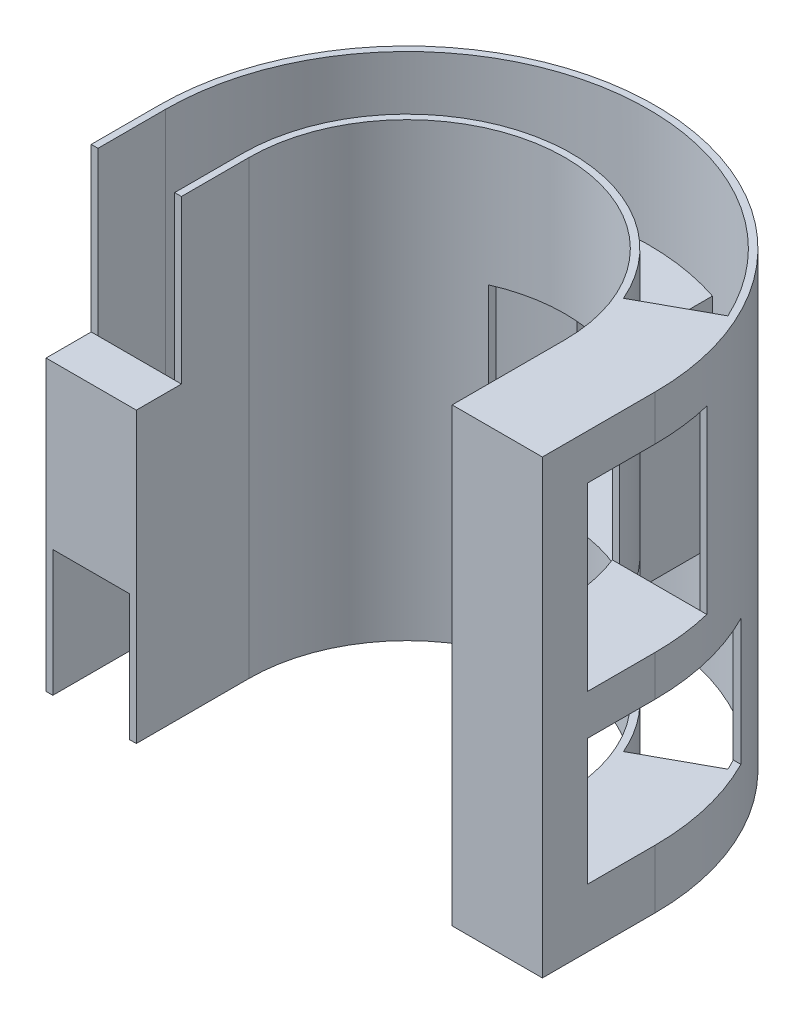
from build123d import *

# Parameters (mm, degrees)
SKETCH2_R            = 27.5
BOSS_EXTRUDE1_DEPTH  = 50
SKETCH3_R            = 26.75
CUT_EXTRUDE1_DEPTH   = 51
SKETCH7_R            = 18.25
BOSS_EXTRUDE3_DEPTH  = 50
SKETCH8_R            = 17.5
CUT_EXTRUDE3_DEPTH   = 51
SKETCH9_W            = 59.961193285
SKETCH9_H            = 28.516087398
CUT_EXTRUDE4_DEPTH   = 51
SKETCH10_W           = 0.75
SKETCH10_H           = 12.5
BOSS_EXTRUDE4_DEPTH  = 50
BOSS_EXTRUDE5_DEPTH  = 5
BOSS_EXTRUDE6_DEPTH  = 6.5
SKETCH12_W           = 14
SKETCH12_H           = 20
SKETCH12_W_2         = 20
SKETCH12_H_2         = 14
CUT_EXTRUDE6_DEPTH   = 15
SKETCH14_W           = 14
SKETCH14_H           = 20
CUT_EXTRUDE7_DEPTH   = 45
SKETCH15_W           = 16.605878589
SKETCH15_H           = 22.2356131
CUT_EXTRUDE8_DEPTH   = 15
BOSS_EXTRUDE8_DEPTH  = 4.5
BOSS_EXTRUDE9_DEPTH  = 2
BOSS_EXTRUDE10_DEPTH = 2
BOSS_EXTRUDE15_DEPTH = 24
BOSS_EXTRUDE17_DEPTH = 10
SKETCH26_W           = 5
SKETCH26_H           = 18
BOSS_EXTRUDE18_DEPTH = 10
SKETCH27_W           = 8.5
SKETCH27_H           = 14
BOSS_EXTRUDE19_DEPTH = 5


with BuildPart() as part:
    # Sketch2 → Boss-Extrude1 (new body)
    with BuildSketch(Plane(origin=(0, 0, 0), x_dir=(1, 0, 0), z_dir=(0, 1, 0))):
        Circle(SKETCH2_R)
    extrude(amount=BOSS_EXTRUDE1_DEPTH)

    # Sketch3 → Cut-Extrude1 (cut, through all)
    with BuildSketch(Plane(origin=(0, 50, 0), x_dir=(1, 0, 0), z_dir=(0, 1, 0))):
        Circle(SKETCH3_R)
    extrude(amount=-CUT_EXTRUDE1_DEPTH, mode=Mode.SUBTRACT)


with BuildPart() as body_2:
    # Sketch7 → Boss-Extrude3 (new body)
    with BuildSketch(Plane(origin=(0, 50, 0), x_dir=(1, 0, 0), z_dir=(0, 1, 0))):
        Circle(SKETCH7_R)
    extrude(amount=-BOSS_EXTRUDE3_DEPTH)

    # Sketch8 → Cut-Extrude3 (cut, through all)
    with BuildSketch(Plane(origin=(0, 50, 0), x_dir=(1, 0, 0), z_dir=(0, 1, 0))):
        Circle(SKETCH8_R)
    extrude(amount=-CUT_EXTRUDE3_DEPTH, mode=Mode.SUBTRACT)


with BuildPart() as cut_extrude4_tool:
    # Sketch9 → Cut-Extrude4 (new body, through all)
    with BuildSketch(Plane(origin=(0, 50, 0), x_dir=(1, 0, 0), z_dir=(0, 1, 0))):
        with Locations((-0.477134602, -14.258043699)):
            Rectangle(SKETCH9_W, SKETCH9_H)
    extrude(amount=-CUT_EXTRUDE4_DEPTH)


with BuildPart() as part_1:
    add(part.part)

    # Cut-Extrude4: cut by cut_extrude4_tool
    add(cut_extrude4_tool.part, mode=Mode.SUBTRACT)



with BuildPart() as body_2_1:
    add(body_2.part)

    # Cut-Extrude4: cut by cut_extrude4_tool
    add(cut_extrude4_tool.part, mode=Mode.SUBTRACT)


with BuildPart() as part_2:
    add(part_1.part)

    add(body_2_1.part)  # Boss-Extrude4 merges body 2
    # Sketch10 → Boss-Extrude4 (add)
    with BuildSketch(Plane(origin=(0, 50, 0), x_dir=(1, 0, 0), z_dir=(0, 1, 0))):
        with Locations((-27.125, -6.25)):
            Rectangle(SKETCH10_W, SKETCH10_H)
        with Locations((-17.875, -6.25)):
            Rectangle(SKETCH10_W, SKETCH10_H)
        with Locations((17.875, -6.25)):
            Rectangle(SKETCH10_W, SKETCH10_H)
        with Locations((27.125, -6.25)):
            Rectangle(SKETCH10_W, SKETCH10_H)
    extrude(amount=-BOSS_EXTRUDE4_DEPTH)

    # Sketch11 → Boss-Extrude5 (add)
    with BuildSketch(Plane(origin=(0, 50, 0), x_dir=(1, 0, 0), z_dir=(0, 1, 0))):
        with BuildLine():
            Line((16.760723177, 7.220848882), (24.236408431, 11.320733473))
            ThreePointArc((24.236408431, 11.320733473), (26.114042444, 5.798214142), (26.75, 0))
            Line((26.75, 0), (26.75, -12.5))
            Line((26.75, -12.5), (18.25, -12.5))
            Line((18.25, -12.5), (18.25, 0))
            ThreePointArc((18.25, 0), (17.873803428, 3.686414384), (16.760723177, 7.220848882))
        make_face()
    extrude(amount=-BOSS_EXTRUDE5_DEPTH)

    # Sketch13 → Boss-Extrude6 (add)
    with BuildSketch(Plane.XZ):
        with BuildLine():
            Line((18.25, 0), (18.25, 12.5))
            Line((18.25, 12.5), (26.75, 12.5))
            Line((26.75, 12.5), (26.75, 0))
            ThreePointArc((26.75, 0), (26.114042444, -5.798214142), (24.236408431, -11.320733473))
            Line((24.236408431, -11.320733473), (16.760723177, -7.220848882))
            ThreePointArc((16.760723177, -7.220848882), (17.873803428, -3.686414384), (18.25, 0))
        make_face()
    extrude(amount=-BOSS_EXTRUDE6_DEPTH)

    # Sketch12 → Cut-Extrude6 (cut)
    with BuildSketch(Plane(origin=(27.5, 0, 0), x_dir=(0, 0, -1), z_dir=(1, 0, 0))):
        with Locations((-0.5, 35)):
            Rectangle(SKETCH12_W, SKETCH12_H)
        with Locations((2.5, 13.5)):
            Rectangle(SKETCH12_W_2, SKETCH12_H_2)
    extrude(amount=-CUT_EXTRUDE6_DEPTH, mode=Mode.SUBTRACT)

    # Sketch14 → Cut-Extrude7 (cut)
    with BuildSketch(Plane.XY.offset(12.5)):
        with Locations((0, 25)):
            Rectangle(SKETCH14_W, SKETCH14_H)
    extrude(amount=-CUT_EXTRUDE7_DEPTH, mode=Mode.SUBTRACT)

    # Sketch15 → Cut-Extrude8 (cut)
    with BuildSketch(Plane.ZY.offset(27.5)):
        with Locations((15.802939295, 43.11780655)):
            Rectangle(SKETCH15_W, SKETCH15_H)
    extrude(amount=-CUT_EXTRUDE8_DEPTH, mode=Mode.SUBTRACT)

    # Sketch17 → Boss-Extrude8 (add)
    with BuildSketch(Plane(origin=(0, 25, 0), x_dir=(1, 0, 0), z_dir=(0, 1, 0))):
        with BuildLine():
            Line((26.720778432, 6.5), (17.053225501, 6.5))
            ThreePointArc((17.053225501, 6.5), (17.948312809, 3.304628164), (18.25, 0))
            Line((18.25, 0), (18.25, -7.5))
            Line((18.25, -7.5), (27.5, -7.5))
            Line((27.5, -7.5), (27.5, 0))
            ThreePointArc((27.5, 0), (27.304499692, 3.273270011), (26.720778432, 6.5))
        make_face()
    extrude(amount=-BOSS_EXTRUDE8_DEPTH)

    # Sketch18 → Boss-Extrude9 (add)
    with BuildSketch(Plane.XZ.offset(-35)):
        with BuildLine():
            Line((-7, -16.854153791), (-7, -25.817871717))
            ThreePointArc((-7, -25.817871717), (0, -26.75), (7, -25.817871717))
            Line((7, -25.817871717), (7, -16.854153791))
            ThreePointArc((7, -16.854153791), (0, -18.25), (-7, -16.854153791))
        make_face()
    extrude(amount=-BOSS_EXTRUDE9_DEPTH)

    # Sketch19 → Boss-Extrude10 (add)
    with BuildSketch(Plane(origin=(0, 15, 0), x_dir=(1, 0, 0), z_dir=(0, 1, 0))):
        with BuildLine():
            Line((7, 25.817871717), (7, 16.854153791))
            ThreePointArc((7, 16.854153791), (0, 18.25), (-7, 16.854153791))
            Line((-7, 16.854153791), (-7, 25.817871717))
            ThreePointArc((-7, 25.817871717), (0, 26.75), (7, 25.817871717))
        make_face()
    extrude(amount=-BOSS_EXTRUDE10_DEPTH)

    # Sketch24 → Boss-Extrude15 (add)
    with BuildSketch(Plane(origin=(0, 37, 0), x_dir=(1, 0, 0), z_dir=(0, 1, 0))):
        with BuildLine():
            Line((8.47493115, 25.37199326), (8.47493115, 16.162859957))
            ThreePointArc((8.47493115, 16.162859957), (7.745182071, 16.524970641), (7, 16.854153791))
            Line((7, 16.854153791), (7, 25.817871717))
            ThreePointArc((7, 25.817871717), (7.740676678, 25.605554565), (8.47493115, 25.37199326))
        make_face()
    extrude(amount=-BOSS_EXTRUDE15_DEPTH)

    # Sketch25 → Boss-Extrude17 (add)
    with BuildSketch(Plane(origin=(27.5, 0, 0), x_dir=(0, 0, -1), z_dir=(1, 0, 0))):
        Polygon((-7.5, 45), (-12.5, 45), (-12.5, 25), (-12.5, 20.5), (-7.5, 20.5), (-7.5, 25), align=None)
    extrude(amount=-BOSS_EXTRUDE17_DEPTH)

    # Sketch26 → Boss-Extrude18 (add)
    with BuildSketch(Plane.ZY.offset(27.5)):
        with Locations((10, 23)):
            Rectangle(SKETCH26_W, SKETCH26_H)
    extrude(amount=-BOSS_EXTRUDE18_DEPTH)

    # Sketch27 → Boss-Extrude19 (add)
    with BuildSketch(Plane.XY.offset(12.5)):
        with Locations((22.5, 13.5)):
            Rectangle(SKETCH27_W, SKETCH27_H)
    extrude(amount=-BOSS_EXTRUDE19_DEPTH)


solid = part_2.part
